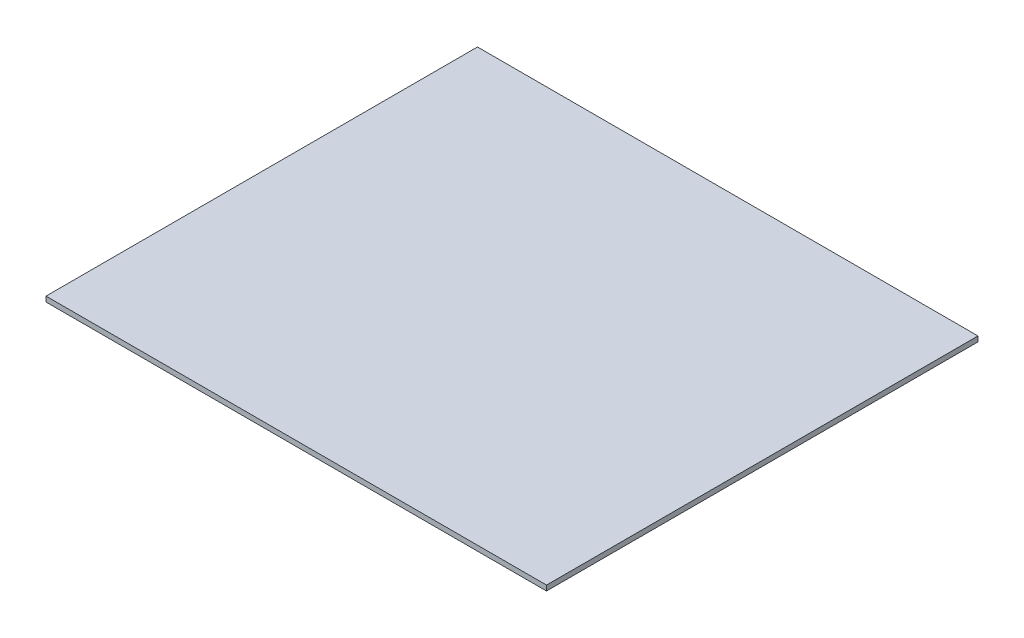
from build123d import *

# Parameters (mm, degrees)
SCHIZZO1_W                   = 580
SCHIZZO1_H                   = 500
ESTRUSIONE_ESTRUSIONE1_DEPTH = 6


with BuildPart() as part:
    # Schizzo1 → Estrusione-Estrusione1 (new body)
    with BuildSketch(Plane.XZ.offset(199.125891028)):
        with Locations((1156.715692012, 581.360192018)):
            Rectangle(SCHIZZO1_W, SCHIZZO1_H)
    extrude(amount=ESTRUSIONE_ESTRUSIONE1_DEPTH)


solid = part.part
